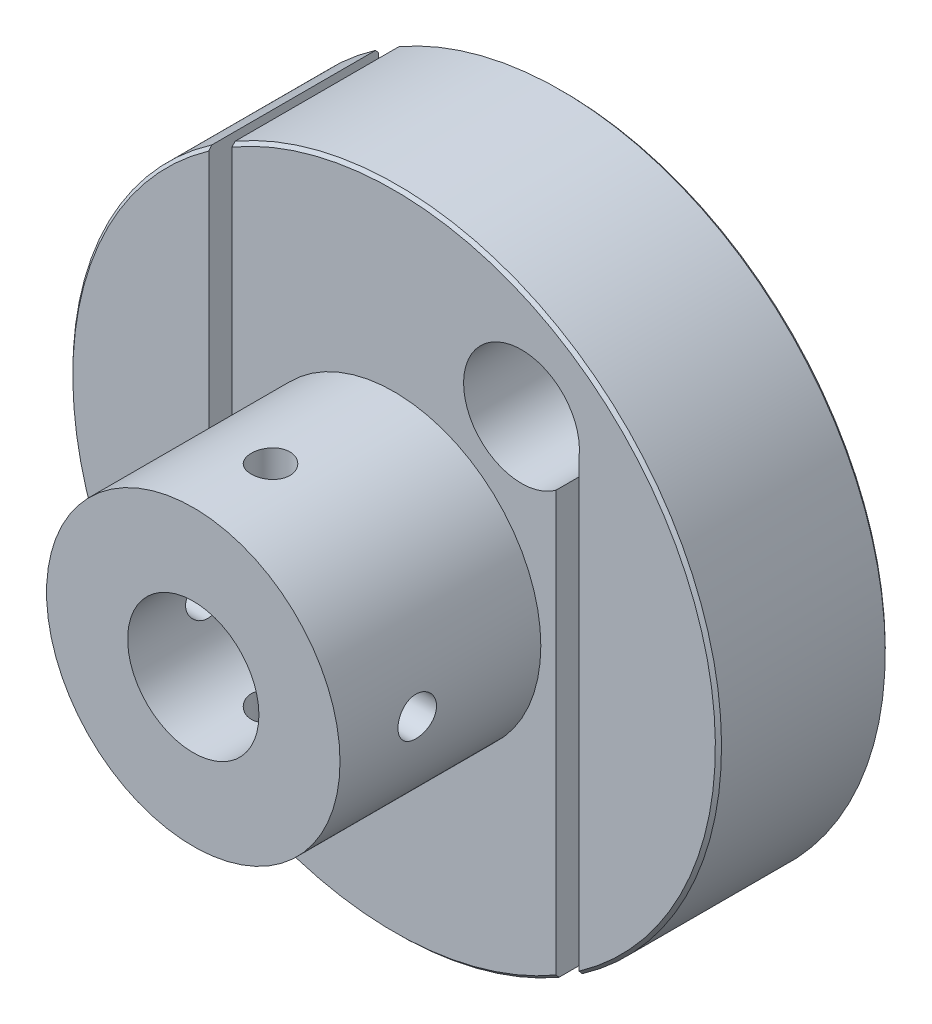
from build123d import *

# Parameters (mm, degrees)
ESQUISSE1_R                               = 21
BOSS_EXTRU_1_DEPTH                        = 11
ESQUISSE2_R                               = 9.5
BOSS_EXTRU_2_DEPTH                        = 13
ESQUISSE3_R                               = 4.25
ENL_V_MAT_EXTRU_1_DEPTH                   = 25
ESQUISSE4_R                               = 3.75
ENL_V_MAT_EXTRU_2_DEPTH                   = 12
ESQUISSE5_W                               = 1.5
ESQUISSE5_H                               = 31.997947006
ESQUISSE5_H_2                             = 31.644558259
ENL_V_MAT_EXTRU_3_DEPTH                   = 12
TROU_POUR_TARAUDAGE_POUR_TROU_TARAUD_M3_D = 2.5
TROU_POUR_TARAUDAGE_POUR_TROU_TARAUD_2_D  = 2.5
CHANFREIN1_SIZE                           = 0.2


with BuildPart() as part:
    # Esquisse1 → Boss.-Extru.1 (new body)
    with BuildSketch(Plane.XY):
        Circle(ESQUISSE1_R)
    extrude(amount=BOSS_EXTRU_1_DEPTH)

    # Esquisse2 → Boss.-Extru.2 (add)
    with BuildSketch(Plane.XY.offset(11)):
        Circle(ESQUISSE2_R)
    extrude(amount=BOSS_EXTRU_2_DEPTH)

    # Esquisse3 → Enlèv. mat.-Extru.1 (cut, through all)
    with BuildSketch(Plane.XY.offset(24)):
        Circle(ESQUISSE3_R)
    extrude(amount=-ENL_V_MAT_EXTRU_1_DEPTH, mode=Mode.SUBTRACT)

    # Esquisse4 → Enlèv. mat.-Extru.2 (cut, through all)
    with BuildSketch(Plane.XY.offset(11)):
        with Locations((8.25, 12.227019261)):
            Circle(ESQUISSE4_R)
        with Locations((-8.25, -12.227019261)):
            Circle(ESQUISSE4_R)
    extrude(amount=-ENL_V_MAT_EXTRU_2_DEPTH, mode=Mode.SUBTRACT)

    # Esquisse5 → Enlèv. mat.-Extru.3 (cut, through all)
    with BuildSketch(Plane.XY.offset(11)):
        with Locations((-11.244697488, 3.971304994)):
            Rectangle(ESQUISSE5_W, ESQUISSE5_H)
        with Locations((11.228919753, -3.198198825)):
            Rectangle(ESQUISSE5_W, ESQUISSE5_H_2)
    extrude(amount=-ENL_V_MAT_EXTRU_3_DEPTH, mode=Mode.SUBTRACT)

    # Trou pour taraudage pour trou taraud_ M3 (through all)
    with Locations(Plane(origin=(0, 10, 0), x_dir=(1, 0, 0), z_dir=(0, 1, 0))):
        with Locations((0, -19)):
            Hole(TROU_POUR_TARAUDAGE_POUR_TROU_TARAUD_M3_D / 2)

    # Trou pour taraudage pour trou taraud 2 (through all)
    with Locations(Plane(origin=(10, 0, 0), x_dir=(0, 0, -1), z_dir=(1, 0, 0))):
        with Locations((-19, 0)):
            Hole(TROU_POUR_TARAUDAGE_POUR_TROU_TARAUD_2_D / 2)

    # Chanfrein1
    chanfrein1_edges = [part.edges().sort_by_distance(p)[0] for p in [
        (-4.25, 0, 0),
        (-17.734235345, -11.24708392, 0),
        (-17.734235345, -11.24708392, 11),
        (17.734504383, 11.246659695, 0),
        (17.734504383, 11.246659695, 11),
    ]]
    chamfer(chanfrein1_edges, length=CHANFREIN1_SIZE)


solid = part.part
